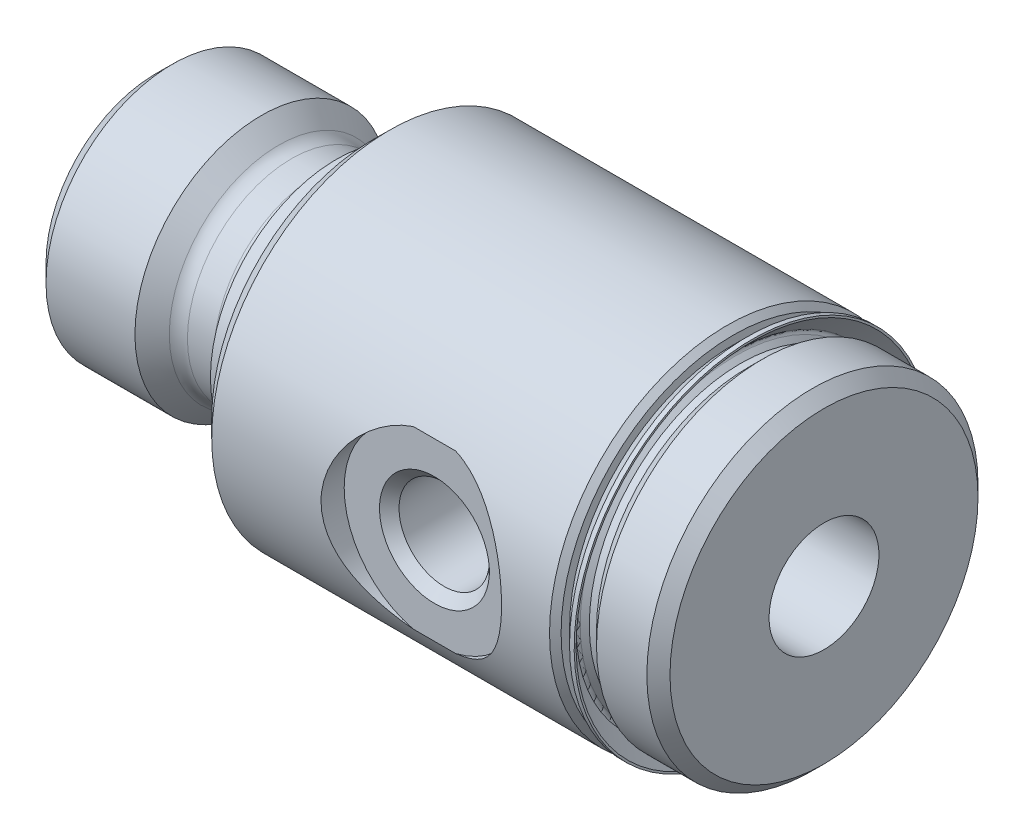
from build123d import *


with BuildPart() as part:
    # Sketch1 → Revolve1 (revolve)
    with BuildSketch(Plane.XY):
        with BuildLine():
            Line((0, 0), (0, 4.8006))
            Line((0, 4.8006), (0.75565, 5.55625))
            Line((0.75565, 5.55625), (4.660293864, 5.55625))
            Line((4.660293864, 5.55625), (5.418103291, 4.804192648))
            ThreePointArc((5.418103291, 4.804192648), (5.676923575, 4.6323221), (5.9817, 4.572))
            Line((5.9817, 4.572), (7.1501, 4.572))
            ThreePointArc((7.1501, 4.572), (7.715856136, 4.806343864), (7.9502, 5.3721))
            Line((7.9502, 5.3721), (7.9502, 5.53085))
            Line((7.9502, 5.53085), (9.525, 5.53085))
            Line((9.525, 5.53085), (9.525, 0))
            Line((9.525, 0), (0, 0))
        make_face()
    revolve(axis=Axis((9.525, 0, 0), (-1, 0, 0)))

    # Sketch2 → Revolve2 (revolve)
    with BuildSketch(Plane.XY):
        Polygon((9.525, 0), (9.525, 7.0485), (10.287, 7.8105), (25.1206, 7.8105), (25.3746, 7.5565), (25.3746, 6.63575), (26.0096, 6.63575), (26.6446, 7.27075), (28.8544, 7.27075), (29.3624, 6.76275), (29.3624, 0), align=None)
    revolve(axis=Axis((29.3624, 0, 0), (-1, 0, 0)))

    # Sketch3 → Cut-Revolve1 (revolve, cut)
    with BuildSketch(Plane.XY):
        Polygon((0, 0), (0, 2.921), (0.508, 2.413), (29.3624, 2.413), (29.3624, 0), align=None)
    revolve(axis=Axis((29.3624, 0, 0), (-1, 0, 0)), mode=Mode.SUBTRACT)

    # Sketch4 → Cut-Revolve2 (revolve, cut)
    with BuildSketch(Plane(origin=(0, 0, 0), x_dir=(1, 0, 0), z_dir=(0, 1, 0))):
        Polygon((19.05, 1.016), (21.03374, 1.016), (21.03374, -6.36524), (21.463, -6.7945), (23.0124, -6.7945), (23.0124, -7.8105), (19.05, -7.8105), align=None)
    revolve(axis=Axis((19.05, 0, 7.8105), (0, 0, -1)), mode=Mode.SUBTRACT)

    # Sketch5 → Revolve3 (revolve)
    with BuildSketch(Plane.XY):
        with BuildLine():
            Line((25.3746, 7.186143808), (25.3746, 6.38175))
            Line((25.3746, 6.38175), (26.0096, 6.38175))
            Line((26.0096, 6.38175), (26.0096, 6.63575))
            Line((26.0096, 6.63575), (25.6921, 6.63575))
            Line((25.6921, 6.63575), (25.491639755, 6.836210245))
            ThreePointArc((25.491639755, 6.836210245), (25.454442316, 6.926012806), (25.491639755, 7.015815367))
            Line((25.491639755, 7.015815367), (26.202156192, 7.726331804))
            Line((26.202156192, 7.726331804), (26.202156192, 7.8105))
            Line((26.202156192, 7.8105), (25.998956192, 7.8105))
            Line((25.998956192, 7.8105), (25.3746, 7.186143808))
        make_face()
    revolve(axis=Axis((26.0096, 0, 0), (-1, 0, 0)))


solid = part.part
